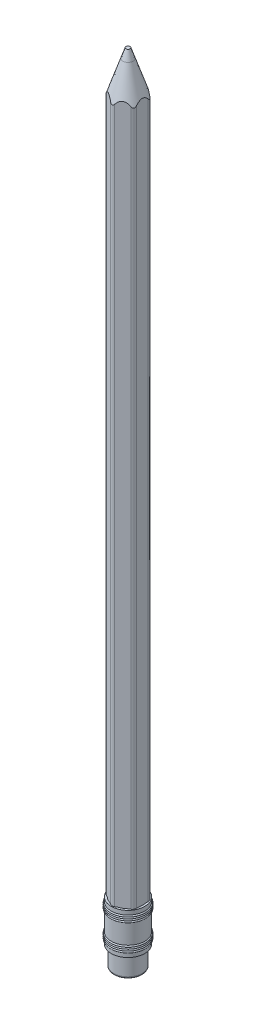
from build123d import *

# Parameters (mm, degrees)
SKETCH1_R           = 1.25
LEAD_DEPTH          = 185
SKETCH2_R           = 1.25
CASE_2_DEPTH        = 185
SKETCH4_R           = 3.5
BOSS_EXTRUDE5_DEPTH = 10
FILLET4_R           = 0.5
FILLET5_R           = 1


with BuildPart() as part:
    # Sketch1 → Lead (new body)
    with BuildSketch(Plane(origin=(0, 0, 0), x_dir=(1, 0, 0), z_dir=(0, 1, 0))):
        Circle(SKETCH1_R)
    extrude(amount=LEAD_DEPTH)


with BuildPart() as body_2:
    # Sketch2 → Case 2 (new body)
    with BuildSketch(Plane.XZ):
        Polygon((-3.5, -2.020725942), (0, -4.041451884), (3.5, -2.020725942), (3.5, 2.020725942), (0, 4.041451884), (-3.5, 2.020725942), align=None)
        Circle(SKETCH2_R, mode=Mode.SUBTRACT)
    extrude(amount=-CASE_2_DEPTH)

    # Fillet5
    fillet5_edges = [body_2.edges().sort_by_distance(p)[0] for p in [
        (0, 92.5, 4.041451884),
        (3.5, 92.5, 2.020725942),
        (3.5, 92.5, -2.020725942),
        (0, 92.5, -4.041451884),
        (-3.5, 92.5, -2.020725942),
        (-3.5, 92.5, 2.020725942),
    ]]
    fillet(fillet5_edges, radius=FILLET5_R)


with BuildPart() as body_3:
    # Sketch4 → Boss-Extrude5 (new body)
    with BuildSketch(Plane.XZ):
        Circle(SKETCH4_R)
    extrude(amount=BOSS_EXTRUDE5_DEPTH)

    # Fillet4
    fillet4_edges = [body_3.edges().sort_by_distance(p)[0] for p in [
        (-3.5, -10, 0),
    ]]
    fillet(fillet4_edges, radius=FILLET4_R)


with BuildPart() as body_4:
    # Sketch6 → Revolve1 (revolve)
    with BuildSketch(Plane.XY):
        with BuildLine():
            Line((-3.6, 5), (-4.1, 5))
            Line((-4.1, 5), (-4.1, 4))
            ThreePointArc((-4.1, 4), (-4.3, 3.8), (-4.1, 3.6))
            ThreePointArc((-4.1, 3.6), (-4.3, 3.4), (-4.1, 3.2))
            ThreePointArc((-4.1, 3.2), (-4.3, 3), (-4.1, 2.8))
            ThreePointArc((-4.1, 2.8), (-4.3, 2.6), (-4.1, 2.4))
            Line((-4.1, 2.4), (-4.1, -2.4))
            ThreePointArc((-4.1, -2.4), (-4.3, -2.6), (-4.1, -2.8))
            ThreePointArc((-4.1, -2.8), (-4.3, -3), (-4.1, -3.2))
            ThreePointArc((-4.1, -3.2), (-4.3, -3.4), (-4.1, -3.6))
            ThreePointArc((-4.1, -3.6), (-4.3, -3.8), (-4.1, -4))
            Line((-4.1, -4), (-4.1, -5))
            Line((-4.1, -5), (-3.6, -5))
            Line((-3.6, -5), (-3.6, -4))
            ThreePointArc((-3.6, -4), (-3.4, -3.8), (-3.6, -3.6))
            ThreePointArc((-3.6, -3.6), (-3.4, -3.4), (-3.6, -3.2))
            ThreePointArc((-3.6, -3.2), (-3.4, -3), (-3.6, -2.8))
            ThreePointArc((-3.6, -2.8), (-3.4, -2.6), (-3.6, -2.4))
            Line((-3.6, -2.4), (-3.6, 2.4))
            ThreePointArc((-3.6, 2.4), (-3.4, 2.6), (-3.6, 2.8))
            ThreePointArc((-3.6, 2.8), (-3.4, 3), (-3.6, 3.2))
            ThreePointArc((-3.6, 3.2), (-3.4, 3.4), (-3.6, 3.6))
            ThreePointArc((-3.6, 3.6), (-3.4, 3.8), (-3.6, 4))
            Line((-3.6, 4), (-3.6, 5))
        make_face()
    revolve(axis=Axis((0, -10, 0), (0, 1, 0)))


with BuildPart() as cut_revolve1_tool:
    # Sketch9 → Cut-Revolve1 (revolve)
    with BuildSketch(Plane.XY):
        Polygon((-0.5, 185), (-5.5, 170), (-5.5, 185), align=None)
    revolve(axis=Axis((0, 185, 0), (0, -1, 0)))


with BuildPart() as part_1:
    add(part.part)

    # Cut-Revolve1: cut by cut_revolve1_tool
    add(cut_revolve1_tool.part, mode=Mode.SUBTRACT)


with BuildPart() as body_2_1:
    add(body_2.part)

    # Cut-Revolve1: cut by cut_revolve1_tool
    add(cut_revolve1_tool.part, mode=Mode.SUBTRACT)


solid = Compound([body_3.part, body_4.part, part_1.part, body_2_1.part])
